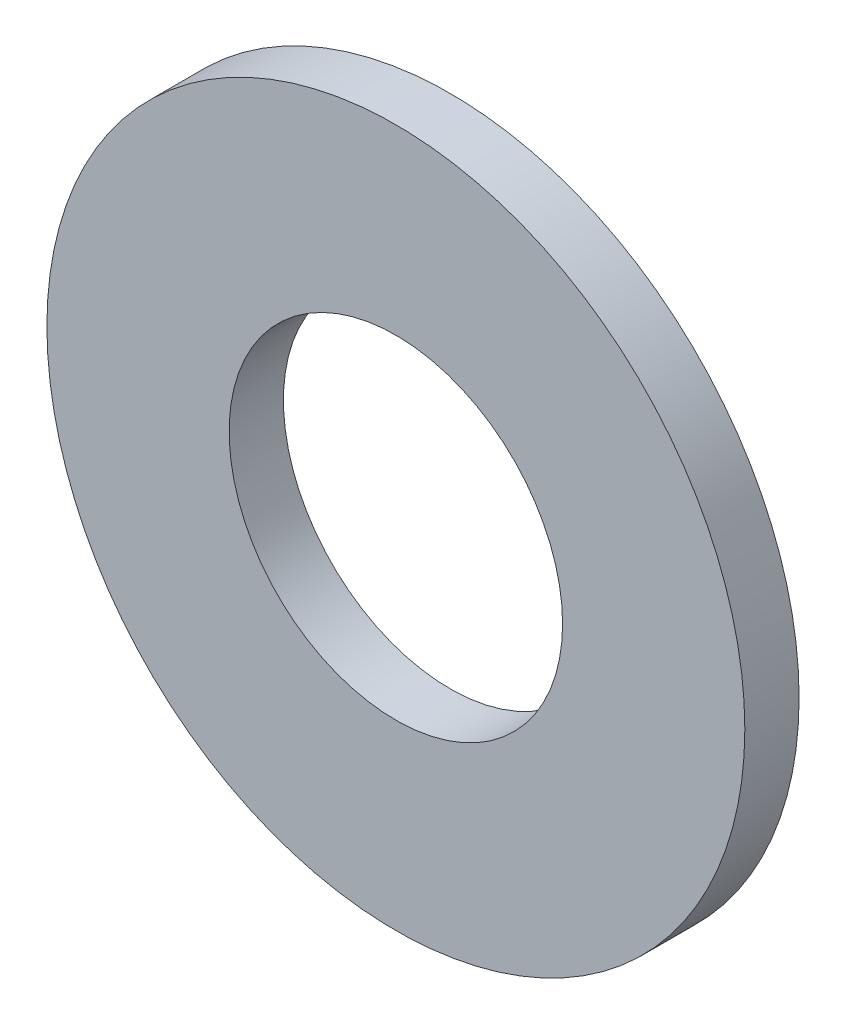
from build123d import *

# Parameters (mm, degrees)
SKETCH1_R      = 4.5
SKETCH1_R_2    = 2.15
EXTRUDE1_DEPTH = 0.7


with BuildPart() as part:
    # Sketch1 → Extrude1 (new body)
    with BuildSketch(Plane.XY):
        Circle(SKETCH1_R)
        Circle(SKETCH1_R_2, mode=Mode.SUBTRACT)
    extrude(amount=-EXTRUDE1_DEPTH)


solid = part.part
